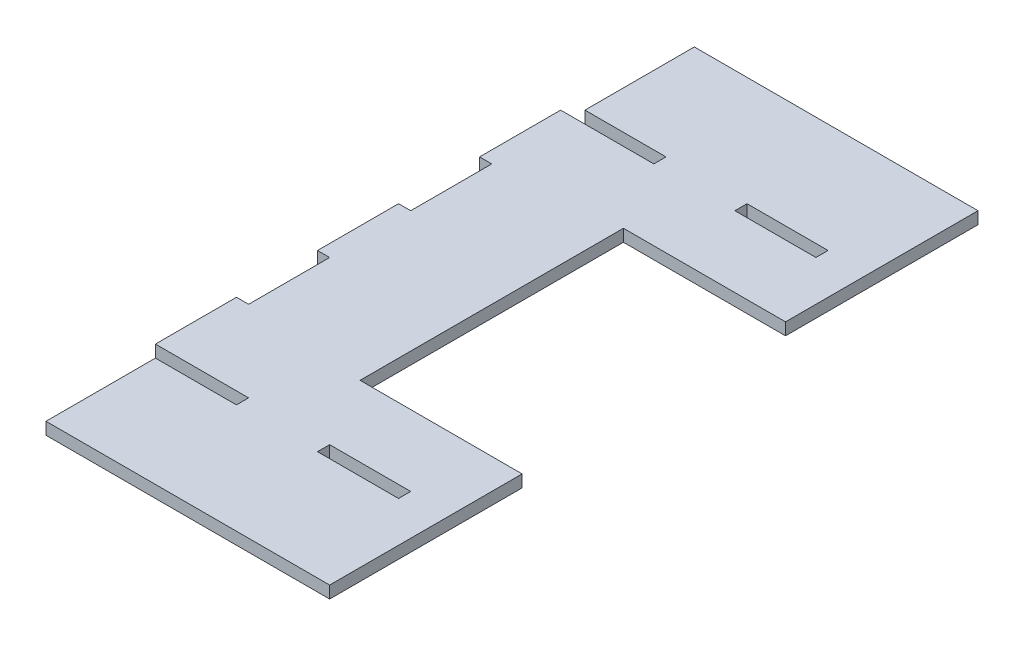
from build123d import *

# Parameters (mm, degrees)
SKETCH1_W           = 70
SKETCH1_H           = 160
BOSS_EXTRUDE1_DEPTH = 3
SKETCH2_W           = 20
SKETCH2_H           = 3
CUT_EXTRUDE1_DEPTH  = 3
SKETCH3_W           = 3
SKETCH3_H           = 20
BOSS_EXTRUDE2_DEPTH = 3
SKETCH5_W           = 40
SKETCH5_H           = 65
CUT_EXTRUDE2_DEPTH  = 25


with BuildPart() as part:
    # Sketch1 → Boss-Extrude1 (new body)
    with BuildSketch(Plane(origin=(0, 0, 0), x_dir=(1, 0, 0), z_dir=(0, 1, 0))):
        with Locations((35, 80)):
            Rectangle(SKETCH1_W, SKETCH1_H)
    extrude(amount=BOSS_EXTRUDE1_DEPTH)

    # Sketch2 → Cut-Extrude1 (cut)
    with BuildSketch(Plane(origin=(0, 3, 0), x_dir=(1, 0, 0), z_dir=(0, 1, 0))):
        with Locations((10, 28.5)):
            Rectangle(SKETCH2_W, SKETCH2_H)
        with Locations((10, 131.5)):
            Rectangle(SKETCH2_W, SKETCH2_H)
        with Locations((50, 131.5)):
            Rectangle(SKETCH2_W, SKETCH2_H)
        with Locations((50, 28.5)):
            Rectangle(SKETCH2_W, SKETCH2_H)
    extrude(amount=-CUT_EXTRUDE1_DEPTH, mode=Mode.SUBTRACT)

    # Sketch3 → Boss-Extrude2 (add)
    with BuildSketch(Plane(origin=(0, 3, 0), x_dir=(1, 0, 0), z_dir=(0, 1, 0))):
        with Locations((-1.5, 120)):
            Rectangle(SKETCH3_W, SKETCH3_H)
        with Locations((-1.5, 80)):
            Rectangle(SKETCH3_W, SKETCH3_H)
        with Locations((-1.5, 40)):
            Rectangle(SKETCH3_W, SKETCH3_H)
    extrude(amount=-BOSS_EXTRUDE2_DEPTH)

    # Sketch5 → Cut-Extrude2 (cut)
    with BuildSketch(Plane(origin=(0, 3, 0), x_dir=(1, 0, 0), z_dir=(0, 1, 0))):
        with Locations((50, 80)):
            Rectangle(SKETCH5_W, SKETCH5_H)
    extrude(amount=-CUT_EXTRUDE2_DEPTH, mode=Mode.SUBTRACT)


solid = part.part
